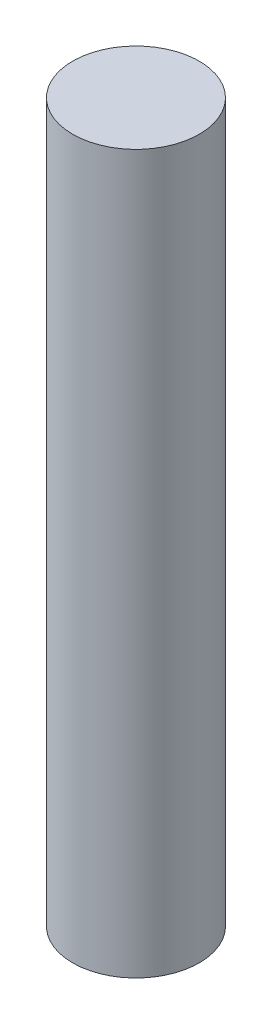
from build123d import *

# Parameters (mm, degrees)
SKETCH1_R           = 7.5
BOSS_EXTRUDE1_DEPTH = 85


with BuildPart() as part:
    # Sketch1 → Boss-Extrude1 (new body)
    with BuildSketch(Plane(origin=(0, 0, 0), x_dir=(1, 0, 0), z_dir=(0, 1, 0))):
        Circle(SKETCH1_R)
    extrude(amount=BOSS_EXTRUDE1_DEPTH)


solid = part.part
